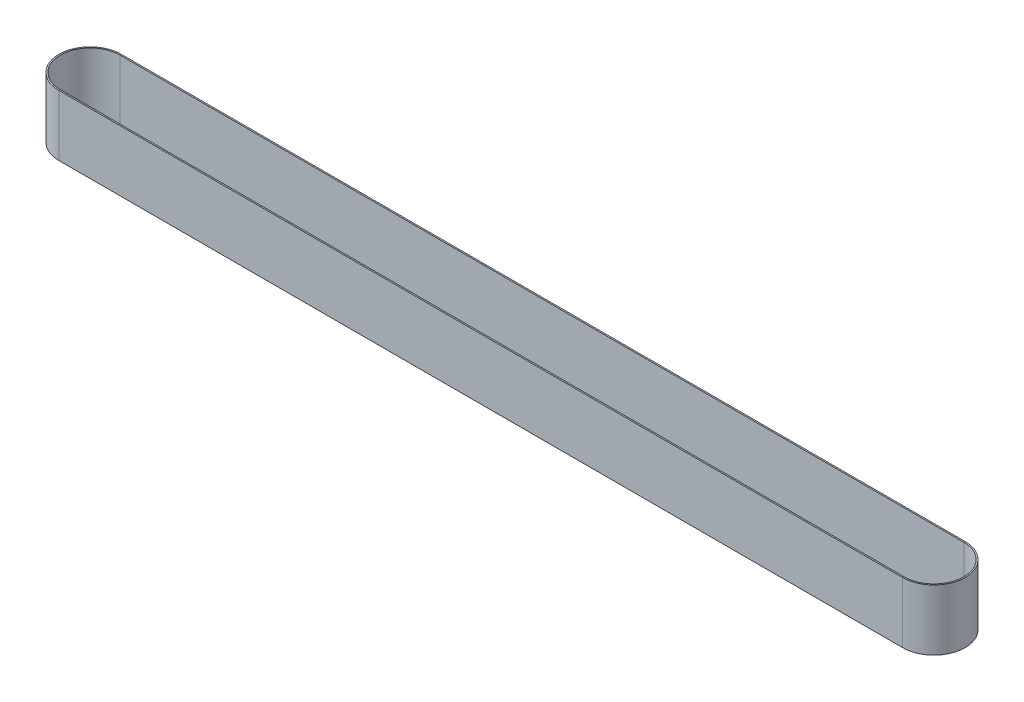
from build123d import *

# Parameters (mm, degrees)
BOSS_EXTRUDE1_DEPTH = 45.72


with BuildPart() as part:
    # Sketch1 → Boss-Extrude1 (new body)
    with BuildSketch(Plane(origin=(0, 0, 0), x_dir=(1, 0, 0), z_dir=(0, 1, 0))):
        with BuildLine():
            Line((0, 23.5), (635, 23.5))
            ThreePointArc((635, 23.5), (658.5, 0), (635, -23.5))
            Line((635, -23.5), (0, -23.5))
            ThreePointArc((0, -23.5), (-23.5, 0), (0, 23.5))
        make_face()
        with BuildLine():
            Line((0, 22.5), (635, 22.5))
            ThreePointArc((635, 22.5), (657.5, 0), (635, -22.5))
            Line((635, -22.5), (0, -22.5))
            ThreePointArc((0, -22.5), (-22.5, 0), (0, 22.5))
        make_face(mode=Mode.SUBTRACT)
    extrude(amount=BOSS_EXTRUDE1_DEPTH)


solid = part.part
